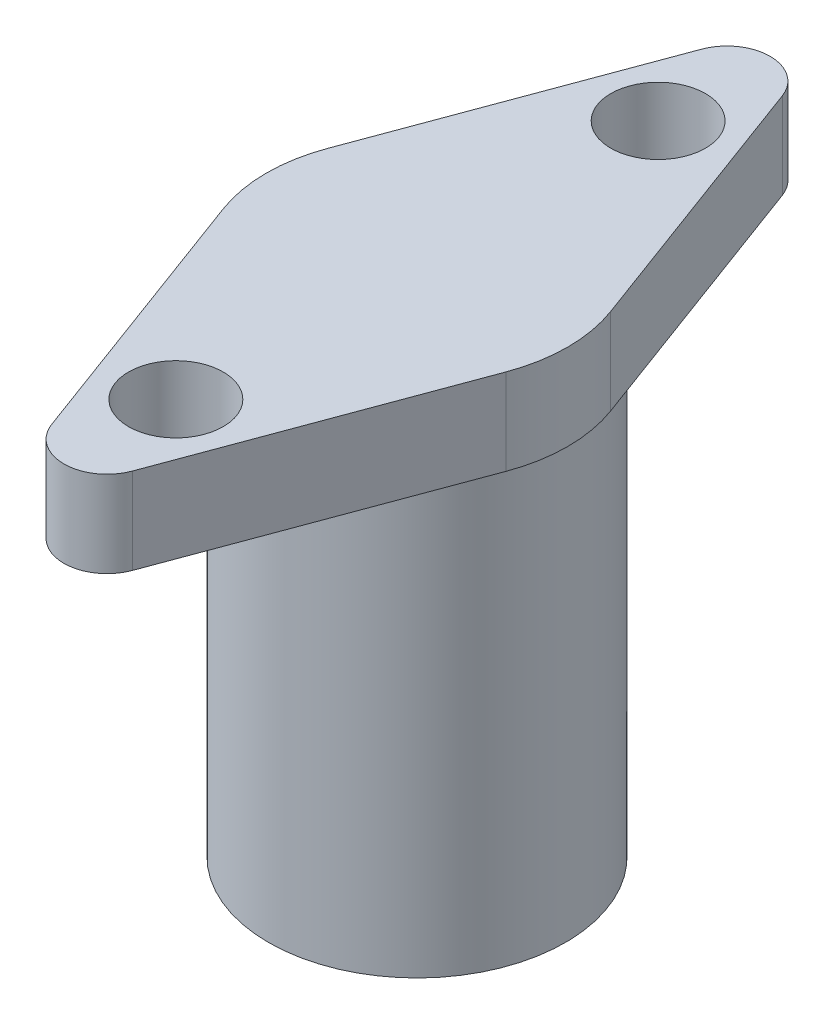
from build123d import *

# Parameters (mm, degrees)
SKETCH1_R           = 3.45
SKETCH1_R_2         = 2.1
BOSS_EXTRUDE1_DEPTH = 10
SKETCH2_R           = 1.1
BOSS_EXTRUDE2_DEPTH = 2


with BuildPart() as part:
    # Sketch1 → Boss-Extrude1 (new body)
    with BuildSketch(Plane(origin=(0, 0, 0), x_dir=(1, 0, 0), z_dir=(0, 1, 0))):
        Circle(SKETCH1_R)
        Circle(SKETCH1_R_2, mode=Mode.SUBTRACT)
    extrude(amount=BOSS_EXTRUDE1_DEPTH)

    # Sketch2 → Boss-Extrude2 (add)
    with BuildSketch(Plane(origin=(0, 10, 0), x_dir=(1, 0, 0), z_dir=(0, 1, 0))):
        with BuildLine():
            Line((-3.282257873, 1.215229712), (-0.937787964, 7.547493269))
            ThreePointArc((-0.937787964, 7.547493269), (0, 8.200284779), (0.937787964, 7.547493269))
            Line((0.937787964, 7.547493269), (3.282257873, 1.215229712))
            ThreePointArc((3.282257873, 1.215229712), (3.5, 0), (3.282257873, -1.215229712))
            Line((3.282257873, -1.215229712), (0.937787964, -7.547493269))
            ThreePointArc((0.937787964, -7.547493269), (0, -8.200284779), (-0.937787964, -7.547493269))
            Line((-0.937787964, -7.547493269), (-3.282257873, -1.215229712))
            ThreePointArc((-3.282257873, -1.215229712), (-3.5, 0), (-3.282257873, 1.215229712))
        make_face()
        with Locations((0, -5.6)):
            Circle(SKETCH2_R, mode=Mode.SUBTRACT)
        with Locations((0, 5.6)):
            Circle(SKETCH2_R, mode=Mode.SUBTRACT)
    extrude(amount=BOSS_EXTRUDE2_DEPTH)


solid = part.part
